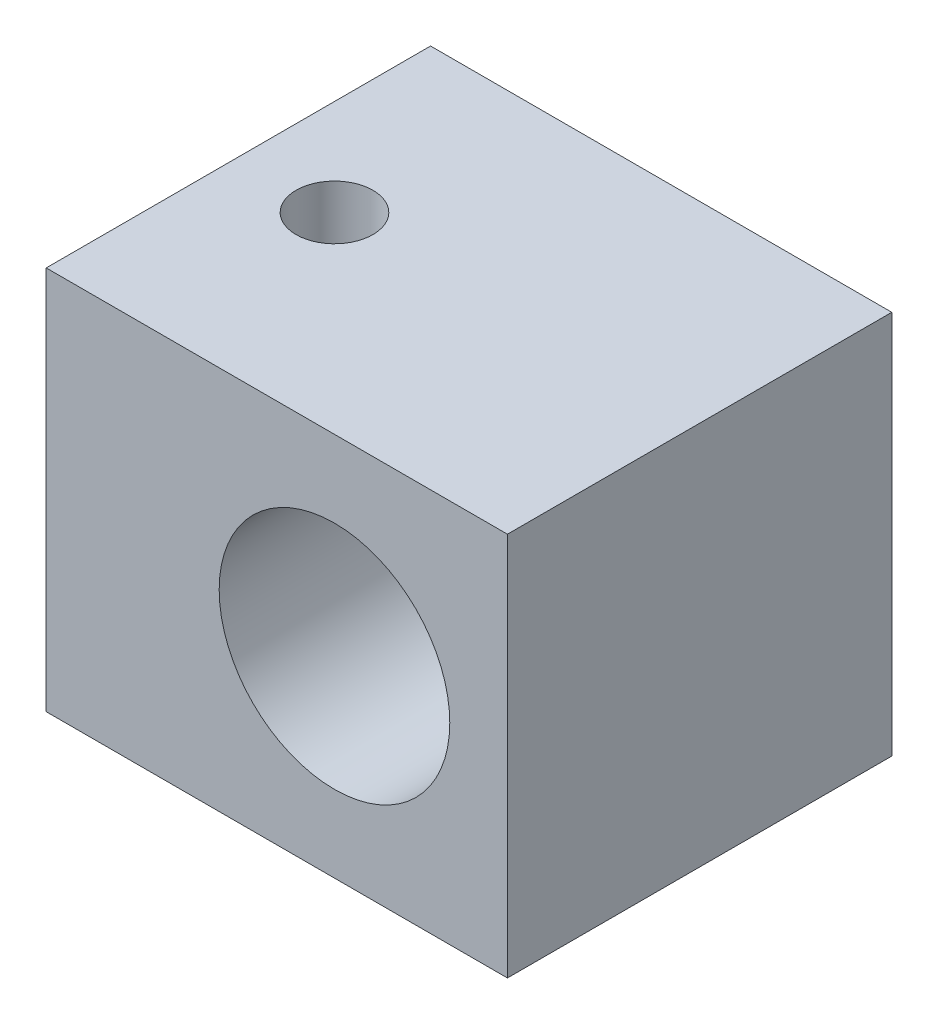
from build123d import *

# Parameters (mm, degrees)
ESQUISSE1_W             = 12
ESQUISSE1_H             = 10
BOSS_EXTRU_1_DEPTH      = 10
ESQUISSE2_R             = 3
ENL_V_MAT_EXTRU_2_DEPTH = 11
ESQUISSE3_R             = 1
ENL_V_MAT_EXTRU_3_DEPTH = 11


with BuildPart() as part:
    # Esquisse1 → Boss.-Extru.1 (new body)
    with BuildSketch(Plane.XY):
        with Locations((6, -5)):
            Rectangle(ESQUISSE1_W, ESQUISSE1_H)
    extrude(amount=BOSS_EXTRU_1_DEPTH)

    # Esquisse2 → Enlèv. mat.-Extru.2 (cut, through all)
    with BuildSketch(Plane.XY):
        with Locations((7.5, -5)):
            Circle(ESQUISSE2_R)
    extrude(amount=ENL_V_MAT_EXTRU_2_DEPTH, mode=Mode.SUBTRACT)

    # Esquisse3 → Enlèv. mat.-Extru.3 (cut, through all)
    with BuildSketch(Plane(origin=(0, 0, 0), x_dir=(1, 0, 0), z_dir=(0, 1, 0))):
        with Locations((2.5, -5)):
            Circle(ESQUISSE3_R)
    extrude(amount=-ENL_V_MAT_EXTRU_3_DEPTH, mode=Mode.SUBTRACT)


solid = part.part
